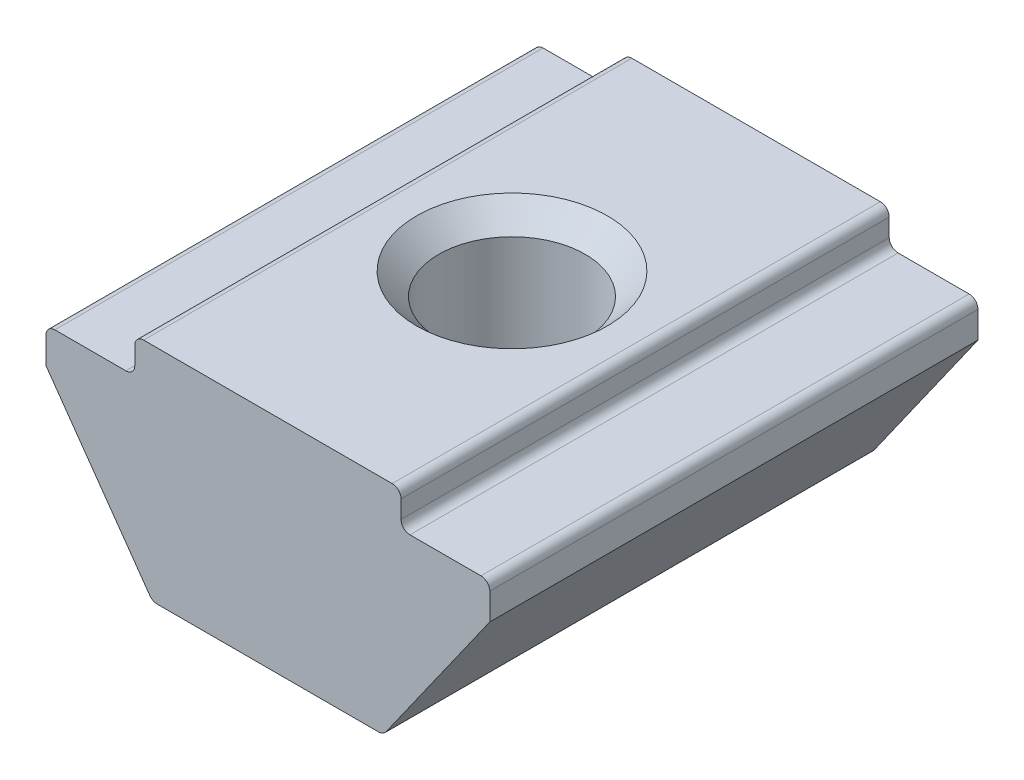
from build123d import *

# Parameters (mm, degrees)
EXTRUDE_1_DEPTH = 5.5
FILLET_1_R      = 0.2


with BuildPart() as part:
    # Эскиз1 → Бобышка-Вытянуть1 (new body, symmetric)
    with BuildSketch(Plane.XY):
        Polygon((3, 0), (-3, 0), (-3, -0.8), (-5, -0.8), (-5, -1.6), (-2.6, -5), (2.6, -5), (5, -1.6), (5, -0.8), (3, -0.8), align=None)
    extrude(amount=EXTRUDE_1_DEPTH, both=True)

    # Эскиз4 → Отверстие обработанное метчиком M41 (revolve, cut)
    with BuildSketch(Plane(origin=(0, 0, 0), x_dir=(0, 0, 1), z_dir=(1, 0, 0))):
        Polygon((0, 0), (0, 5), (2.15, 5), (1.65, 4.5), (1.65, 0.5), (2.15, 0), align=None)
    revolve(axis=Axis((0, 6.35, 0), (0, -1, 0)), mode=Mode.SUBTRACT)

    # Скругление1
    fillet_1_edges = [part.edges().sort_by_distance(p)[0] for p in [
        (-3, 0, 0),
        (3, 0, 0),
        (3, -0.8, 0),
        (5, -0.8, 0),
        (2.6, -5, 0),
        (-2.6, -5, 0),
        (-5, -0.8, 0),
        (-3, -0.8, 0),
    ]]
    fillet(fillet_1_edges, radius=FILLET_1_R)


solid = part.part
